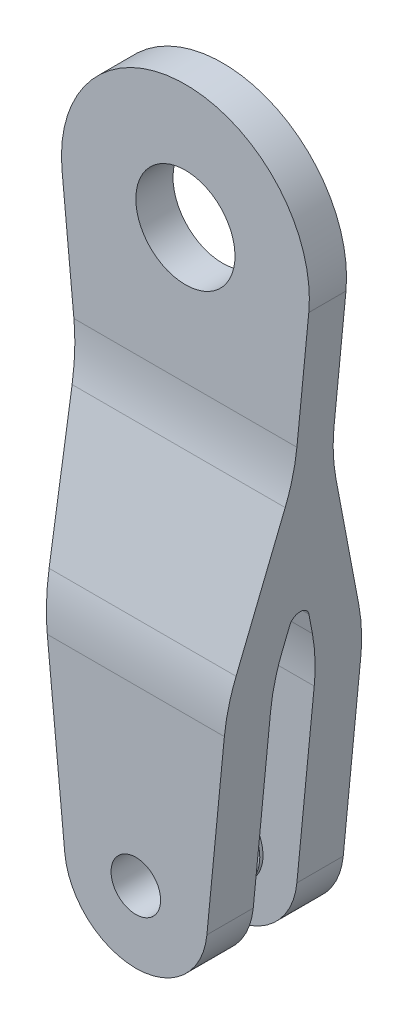
from build123d import *

# Parameters (mm, degrees)
SKETCH1_R               = 3.175
SKETCH1_R_2             = 6.35
BOSS_EXTRUDE1_DEPTH     = 8.73125
CUT_EXTRUDE1_DEPTH      = 16.875
CUT_EXTRUDE1_DEPTH_BACK = 16.875
SKETCH3_R               = 4.7625
SKETCH3_R_2             = 3.175
BOSS_EXTRUDE2_DEPTH     = 6.35
FILLET1_R               = 25.4
FILLET2_R               = 1.27


with BuildPart() as part:
    # Sketch1 → Boss-Extrude1 (new body, symmetric)
    with BuildSketch(Plane.XY):
        with BuildLine():
            Line((-15.801120859, 68.320227273), (-9.101445615, -0.881149091))
            ThreePointArc((-9.101445615, -0.881149091), (0, -9.144), (9.101445615, -0.881149091))
            Line((9.101445615, -0.881149091), (15.801120859, 68.320227273))
            ThreePointArc((15.801120859, 68.320227273), (0, 85.725), (-15.801120859, 68.320227273))
        make_face()
        Circle(SKETCH1_R, mode=Mode.SUBTRACT)
        with Locations((0, 69.85)):
            Circle(SKETCH1_R_2, mode=Mode.SUBTRACT)
    extrude(amount=BOSS_EXTRUDE1_DEPTH, both=True)

    # Sketch2 → Cut-Extrude1 (cut, two sides)
    with BuildSketch(Plane(origin=(0, -0.404650896, 0), x_dir=(0, 0, -1), z_dir=(1, 0, 0))) as cut_extrude1_sk:
        Polygon((-2.38125, 49.674878169), (-2.38125, 86.129650896), (-8.73125, 86.129650896), (-8.73125, 68.724878169), (-8.73125, 25.976355541), align=None)
        Polygon((8.73125, 68.724878169), (8.73125, 86.129650896), (2.38125, 86.129650896), (2.38125, 49.674878169), (8.73125, 25.976355541), align=None)
        Polygon((-2.794, 25.804650896), (-2.794, -8.739349104), (2.794, -8.739349104), (2.794, 25.804650896), (0, 36.232000852), align=None)
    extrude(amount=CUT_EXTRUDE1_DEPTH, mode=Mode.SUBTRACT)
    extrude(cut_extrude1_sk.sketch, amount=-CUT_EXTRUDE1_DEPTH_BACK, mode=Mode.SUBTRACT)

    # Sketch3 → Boss-Extrude2 (add)
    with BuildSketch(Plane.XY.offset(8.73125)):
        Circle(SKETCH3_R)
        Circle(SKETCH3_R_2, mode=Mode.SUBTRACT)
    boss_extrude2 = extrude(amount=-BOSS_EXTRUDE2_DEPTH)

    # Mirror1: Boss-Extrude2 across plane
    add(boss_extrude2.mirror(Plane.XY))

    # Fillet1
    fillet1_edges = [part.edges().sort_by_distance(p)[0] for p in [
        (0, 25.571704645, -8.73125),
        (0, 49.270227273, -2.38125),
        (0, 25.4, 2.794),
        (0, 25.4, -2.794),
        (0, 49.270227273, 2.38125),
        (0, 25.571704645, 8.73125),
    ]]
    fillet(fillet1_edges, radius=FILLET1_R)

    # Fillet2
    fillet2_edges = [part.edges().sort_by_distance(p)[0] for p in [
        (0, 35.827349956, 0),
    ]]
    fillet(fillet2_edges, radius=FILLET2_R)


solid = part.part
